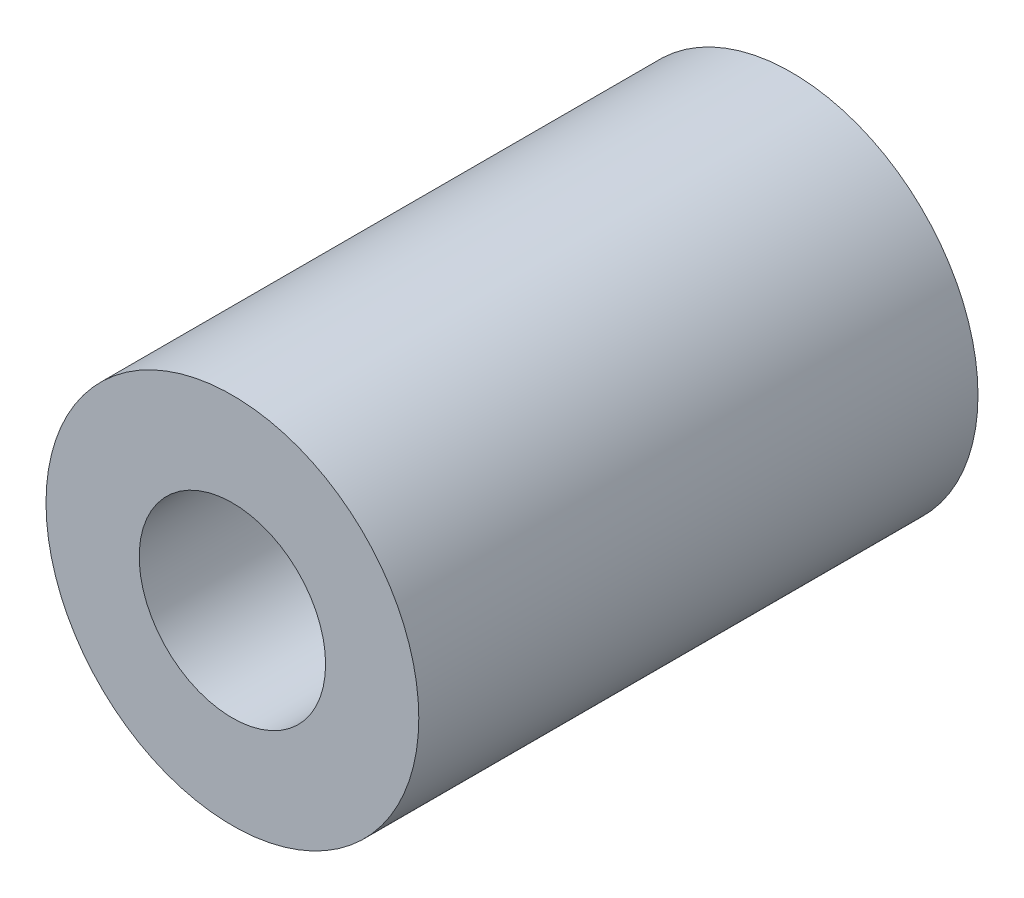
from build123d import *

# Parameters (mm, degrees)
ESQUISSE1_R        = 2
ESQUISSE1_R_2      = 1
BOSS_EXTRU_1_DEPTH = 6


with BuildPart() as part:
    # Esquisse1 → Boss.-Extru.1 (new body)
    with BuildSketch(Plane.XY):
        Circle(ESQUISSE1_R)
        Circle(ESQUISSE1_R_2, mode=Mode.SUBTRACT)
    extrude(amount=BOSS_EXTRU_1_DEPTH)


solid = part.part
